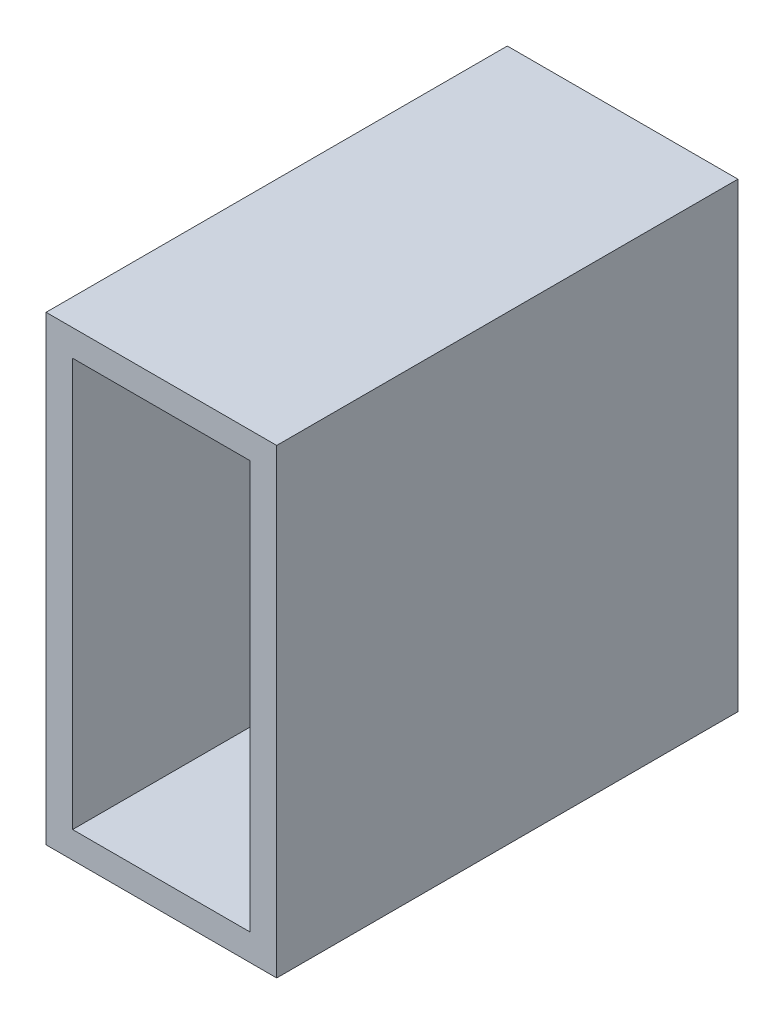
from build123d import *

# Parameters (mm, degrees)
SKETCH1_W           = 25.4
SKETCH1_H           = 50.8
SKETCH1_W_2         = 19.558
SKETCH1_H_2         = 44.958
BOSS_EXTRUDE1_DEPTH = 50.8


with BuildPart() as part:
    # Sketch1 → Boss-Extrude1 (new body)
    with BuildSketch(Plane.XY):
        Rectangle(SKETCH1_W, SKETCH1_H)
        Rectangle(SKETCH1_W_2, SKETCH1_H_2, mode=Mode.SUBTRACT)
    extrude(amount=BOSS_EXTRUDE1_DEPTH)


solid = part.part
